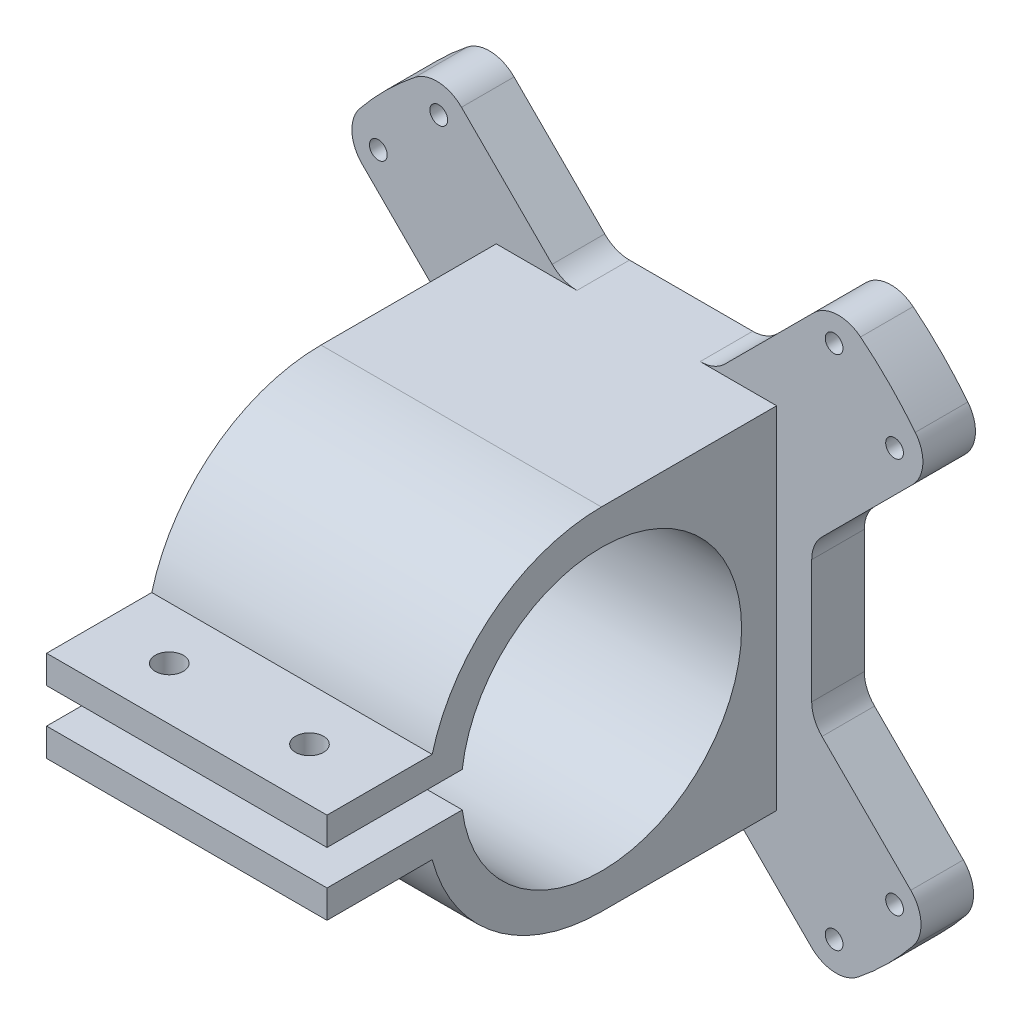
from build123d import *

# Parameters (mm, degrees)
SKETCH8_R           = 1.266
BOSS_EXTRUDE3_DEPTH = 7.5
BOSS_EXTRUDE4_DEPTH = 20
SKETCH10_R          = 2
CUT_EXTRUDE3_DEPTH  = 13


with BuildPart() as part:
    # Sketch8 → Boss-Extrude3 (new body)
    with BuildSketch(Plane.XY):
        with BuildLine():
            Line((-26.464466094, 12.621101614), (-39.129662609, 25.286298129))
            ThreePointArc((-39.129662609, 25.286298129), (-40.587272547, 28.560079176), (-39.479950614, 31.968320248))
            ThreePointArc((-39.479950614, 31.968320248), (-35.753947361, 36.087328082), (-31.600536501, 39.774943028))
            ThreePointArc((-31.600536501, 39.774943028), (-28.205326911, 40.851961857), (-24.954713569, 39.395620337))
            Line((-24.954713569, 39.395620337), (-12.023559327, 26.464466094))
            ThreePointArc((-12.023559327, 26.464466094), (-10.401442583, 25.380602337), (-8.488025421, 25))
            Line((-8.488025421, 25), (9.085567708, 25))
            ThreePointArc((9.085567708, 25), (10.99898487, 25.380602337), (12.621101614, 26.464466094))
            Line((12.621101614, 26.464466094), (25.286298129, 39.129662609))
            ThreePointArc((25.286298129, 39.129662609), (28.560079176, 40.587272547), (31.968320248, 39.479950614))
            ThreePointArc((31.968320248, 39.479950614), (36.087328082, 35.753947361), (39.774943028, 31.600536501))
            ThreePointArc((39.774943028, 31.600536501), (40.851961857, 28.205326911), (39.395620337, 24.954713569))
            Line((39.395620337, 24.954713569), (26.464466094, 12.023559327))
            ThreePointArc((26.464466094, 12.023559327), (25.380602337, 10.401442583), (25, 8.488025421))
            Line((25, 8.488025421), (25, -9.085567708))
            ThreePointArc((25, -9.085567708), (25.380602337, -10.99898487), (26.464466094, -12.621101614))
            Line((26.464466094, -12.621101614), (39.129662609, -25.286298129))
            ThreePointArc((39.129662609, -25.286298129), (40.587272547, -28.560079176), (39.479950614, -31.968320248))
            ThreePointArc((39.479950614, -31.968320248), (35.753947361, -36.087328082), (31.600536501, -39.774943028))
            ThreePointArc((31.600536501, -39.774943028), (28.205326911, -40.851961857), (24.954713569, -39.395620337))
            Line((24.954713569, -39.395620337), (12.023559327, -26.464466094))
            ThreePointArc((12.023559327, -26.464466094), (10.401442583, -25.380602337), (8.488025421, -25))
            Line((8.488025421, -25), (-9.085567708, -25))
            ThreePointArc((-9.085567708, -25), (-10.99898487, -25.380602337), (-12.621101614, -26.464466094))
            Line((-12.621101614, -26.464466094), (-25.286298129, -39.129662609))
            ThreePointArc((-25.286298129, -39.129662609), (-28.560079176, -40.587272547), (-31.968320248, -39.479950614))
            ThreePointArc((-31.968320248, -39.479950614), (-36.087328082, -35.753947361), (-39.774943028, -31.600536501))
            ThreePointArc((-39.774943028, -31.600536501), (-40.851961857, -28.205326911), (-39.395620337, -24.954713569))
            Line((-39.395620337, -24.954713569), (-26.464466094, -12.023559327))
            ThreePointArc((-26.464466094, -12.023559327), (-25.380602337, -10.401442583), (-25, -8.488025421))
            Line((-25, -8.488025421), (-25, 9.085567708))
            ThreePointArc((-25, 9.085567708), (-25.380602337, 10.99898487), (-26.464466094, 12.621101614))
        make_face()
        with Locations((-28.19800422, -36.819050096)):
            Circle(SKETCH8_R, mode=Mode.SUBTRACT)
        with Locations((-36.819050096, -28.19800422)):
            Circle(SKETCH8_R, mode=Mode.SUBTRACT)
        with Locations((-36.819050096, 28.19800422)):
            Circle(SKETCH8_R, mode=Mode.SUBTRACT)
        with Locations((-28.19800422, 36.819050096)):
            Circle(SKETCH8_R, mode=Mode.SUBTRACT)
        with Locations((28.19800422, 36.819050096)):
            Circle(SKETCH8_R, mode=Mode.SUBTRACT)
        with Locations((36.819050096, 28.19800422)):
            Circle(SKETCH8_R, mode=Mode.SUBTRACT)
        with Locations((36.819050096, -28.19800422)):
            Circle(SKETCH8_R, mode=Mode.SUBTRACT)
        with Locations((28.19800422, -36.819050096)):
            Circle(SKETCH8_R, mode=Mode.SUBTRACT)
    extrude(amount=BOSS_EXTRUDE3_DEPTH)

    # Sketch9 → Boss-Extrude4 (add, symmetric)
    with BuildSketch(Plane(origin=(0, 0, 0), x_dir=(0, 0, -1), z_dir=(1, 0, 0))):
        with BuildLine():
            Line((-7.5, -25), (-7.5, 25))
            Line((-7.5, 25), (-32.5, 25))
            ThreePointArc((-32.5, 25), (-47.706906326, 19.843134833), (-56.640215409, 6.5))
            Line((-56.640215409, 6.5), (-71.640215409, 6.5))
            Line((-71.640215409, 6.5), (-71.640215409, 2.5))
            Line((-71.640215409, 2.5), (-52.343134833, 2.5))
            ThreePointArc((-52.343134833, 2.5), (-12.5, 0), (-52.343134833, -2.5))
            Line((-52.343134833, -2.5), (-71.640215409, -2.5))
            Line((-71.640215409, -2.5), (-71.640215409, -6.5))
            Line((-71.640215409, -6.5), (-56.640215409, -6.5))
            ThreePointArc((-56.640215409, -6.5), (-47.706906326, -19.843134833), (-32.5, -25))
            Line((-32.5, -25), (-7.5, -25))
        make_face()
    extrude(amount=BOSS_EXTRUDE4_DEPTH, both=True)

    # Sketch10 → Cut-Extrude3 (cut)
    with BuildSketch(Plane(origin=(0, 6.5, 0), x_dir=(1, 0, 0), z_dir=(0, 1, 0))):
        with Locations((-10, -64.140215409)):
            Circle(SKETCH10_R)
        with Locations((10, -64.140215409)):
            Circle(SKETCH10_R)
    extrude(amount=-CUT_EXTRUDE3_DEPTH, mode=Mode.SUBTRACT)


solid = part.part
